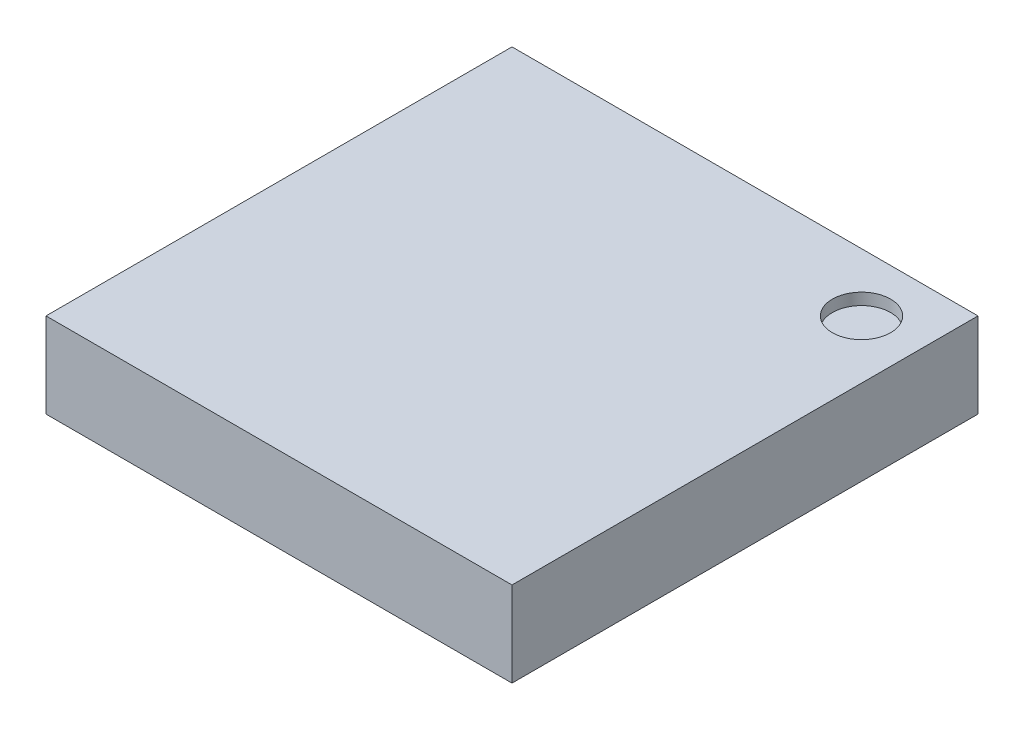
from build123d import *

# Parameters (mm, degrees)
SKETCH1_W           = 4
SKETCH1_H           = 4
BOSS_EXTRUDE1_DEPTH = 0.73
SKETCH2_R           = 0.25
CUT_EXTRUDE1_DEPTH  = 0.1


with BuildPart() as part:
    # Sketch1 → Boss-Extrude1 (new body)
    with BuildSketch(Plane(origin=(0, 0, 0), x_dir=(1, 0, 0), z_dir=(0, 1, 0))):
        Rectangle(SKETCH1_W, SKETCH1_H)
    extrude(amount=BOSS_EXTRUDE1_DEPTH)

    # Sketch2 → Cut-Extrude1 (cut)
    with BuildSketch(Plane(origin=(0, 0.73, 0), x_dir=(1, 0, 0), z_dir=(0, 1, 0))):
        with Locations((1.5, 1.5)):
            Circle(SKETCH2_R)
    extrude(amount=-CUT_EXTRUDE1_DEPTH, mode=Mode.SUBTRACT)


solid = part.part
